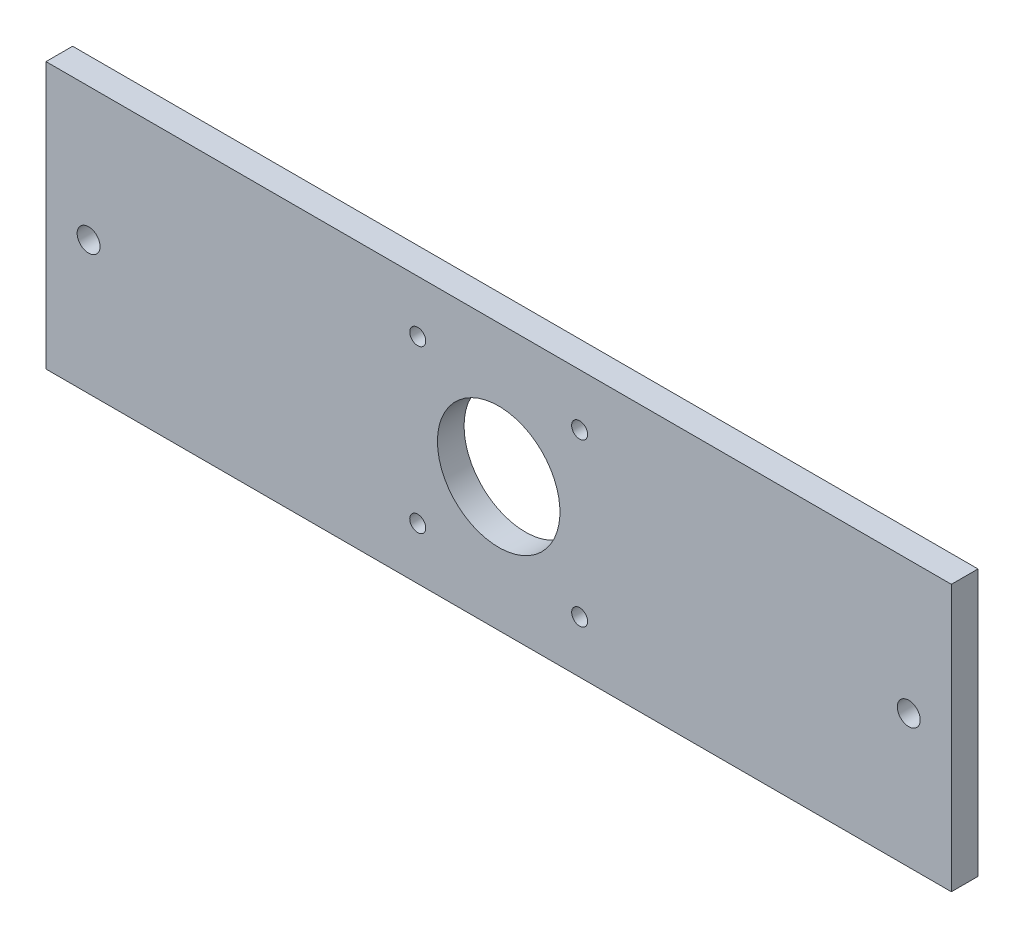
from build123d import *

# Parameters (mm, degrees)
ESBO_O1_W                  = 50
ESBO_O1_H                  = 50
RESSALTO_EXTRUS_O1_DEPTH   = 5
ESBO_O2_R                  = 11.5
CORTE_EXTRUS_O1_DEPTH      = 8
CORTE_EXTRUS_O1_DEPTH_BACK = 14
ESBO_O3_W                  = 60
ESBO_O3_H                  = 50
RESSALTO_EXTRUS_O2_DEPTH   = 5
ESBO_O4_R                  = 2.15
ESBO_O4_R_2                = 1.5
CORTE_EXTRUS_O2_DEPTH      = 19
CORTE_EXTRUS_O2_DEPTH_BACK = 12


with BuildPart() as part:
    # Esboço1 → Ressalto-extrusão1 (new body)
    with BuildSketch(Plane.XY):
        with Locations((25, 25)):
            Rectangle(ESBO_O1_W, ESBO_O1_H)
    extrude(amount=RESSALTO_EXTRUS_O1_DEPTH)

    # Esboço2 → Corte-extrusão1 (cut, two sides)
    with BuildSketch(Plane.XY) as corte_extrus_o1_sk:
        with Locations((25, 25)):
            Circle(ESBO_O2_R)
    extrude(amount=CORTE_EXTRUS_O1_DEPTH, mode=Mode.SUBTRACT)
    extrude(corte_extrus_o1_sk.sketch, amount=-CORTE_EXTRUS_O1_DEPTH_BACK, mode=Mode.SUBTRACT)

    # Esboço3 → Ressalto-extrusão2 (add)
    with BuildSketch(Plane.XY):
        with Locations((-30, 25)):
            Rectangle(ESBO_O3_W, ESBO_O3_H)
        with Locations((80, 25)):
            Rectangle(ESBO_O3_W, ESBO_O3_H)
    extrude(amount=RESSALTO_EXTRUS_O2_DEPTH)

    # Esboço4 → Corte-extrusão2 (cut, two sides)
    with BuildSketch(Plane.XY) as corte_extrus_o2_sk:
        with Locations((-52, 25)):
            Circle(ESBO_O4_R)
        with Locations((102, 25)):
            Circle(ESBO_O4_R)
        with Locations((9.8, 40.2)):
            Circle(ESBO_O4_R_2)
        with Locations((40.2, 40.2)):
            Circle(ESBO_O4_R_2)
        with Locations((40.2, 9.8)):
            Circle(ESBO_O4_R_2)
        with Locations((9.8, 9.8)):
            Circle(ESBO_O4_R_2)
    extrude(amount=CORTE_EXTRUS_O2_DEPTH, mode=Mode.SUBTRACT)
    extrude(corte_extrus_o2_sk.sketch, amount=-CORTE_EXTRUS_O2_DEPTH_BACK, mode=Mode.SUBTRACT)


solid = part.part
